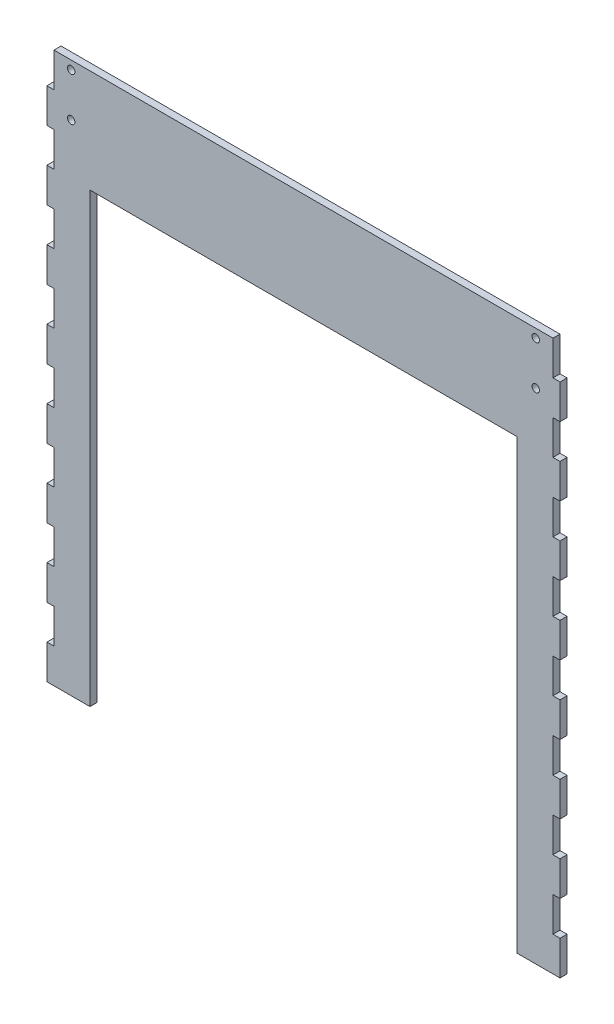
from build123d import *

# Parameters (mm, degrees)
SKETCH1_R           = 2.75
BOSS_EXTRUDE1_DEPTH = 5.207


with BuildPart() as part:
    # Sketch1 → Boss-Extrude1 (new body)
    with BuildSketch(Plane.XY):
        Polygon((-189.357, 25.4), (-189.357, 0), (-157.607, 0), (-157.607, 330.2), (157.607, 330.2), (157.607, 0), (189.357, 0), (189.357, 25.4), (184.15, 25.4), (184.15, 50.8), (189.357, 50.8), (189.357, 76.2), (184.15, 76.2), (184.15, 101.6), (189.357, 101.6), (189.357, 127), (184.15, 127), (184.15, 152.4), (189.357, 152.4), (189.357, 177.8), (184.15, 177.8), (184.15, 203.2), (189.357, 203.2), (189.357, 228.6), (184.15, 228.6), (184.15, 254), (189.357, 254), (189.357, 279.4), (184.15, 279.4), (184.15, 304.8), (189.357, 304.8), (189.357, 330.2), (184.15, 330.2), (184.15, 355.6), (189.357, 355.6), (189.357, 381), (184.15, 381), (184.15, 406.4), (-184.15, 406.4), (-184.15, 381), (-189.357, 381), (-189.357, 355.6), (-184.15, 355.6), (-184.15, 330.2), (-189.357, 330.2), (-189.357, 304.8), (-184.15, 304.8), (-184.15, 279.4), (-189.357, 279.4), (-189.357, 254), (-184.15, 254), (-184.15, 228.6), (-189.357, 228.6), (-189.357, 203.2), (-184.15, 203.2), (-184.15, 177.8), (-189.357, 177.8), (-189.357, 152.4), (-184.15, 152.4), (-184.15, 127), (-189.357, 127), (-189.357, 101.6), (-184.15, 101.6), (-184.15, 76.2), (-189.357, 76.2), (-189.357, 50.8), (-184.15, 50.8), (-184.15, 25.4), align=None)
        with Locations((-171.45, 368.05)):
            Circle(SKETCH1_R, mode=Mode.SUBTRACT)
        with Locations((-171.45, 400.05)):
            Circle(SKETCH1_R, mode=Mode.SUBTRACT)
        with Locations((171.45, 368.05)):
            Circle(SKETCH1_R, mode=Mode.SUBTRACT)
        with Locations((171.45, 400.05)):
            Circle(SKETCH1_R, mode=Mode.SUBTRACT)
    extrude(amount=BOSS_EXTRUDE1_DEPTH)


solid = part.part
